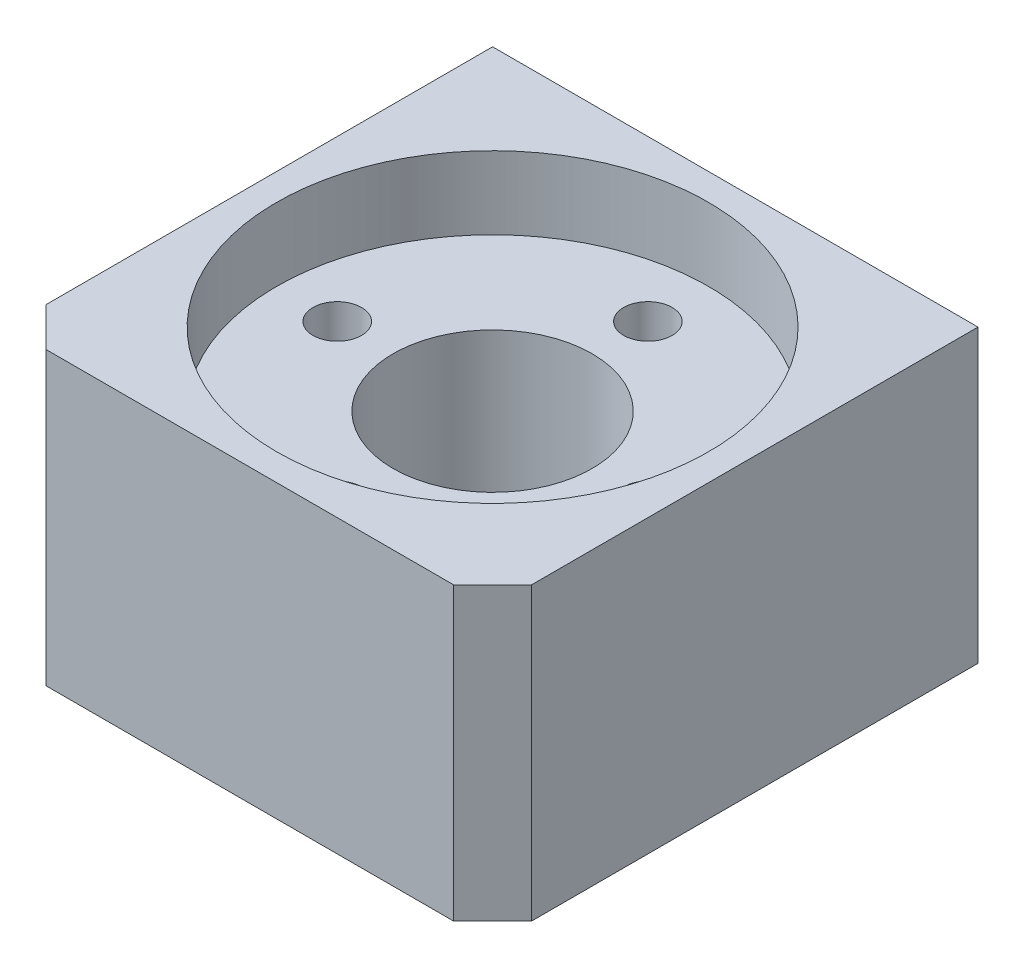
from build123d import *

# Parameters (mm, degrees)
SKETCH1_W                 = 25
SKETCH1_H                 = 25
BOSS_EXTRUDE1_DEPTH       = 15
SKETCH2_R                 = 11.125
CUT_EXTRUDE1_DEPTH        = 3.75
SKETCH3_R                 = 5.125
CUT_EXTRUDE2_DEPTH        = 12.25
M3X0_5_TAPPED_HOLE1_D     = 2.5
M3X0_5_TAPPED_HOLE1_DEPTH = 6
M3X0_5_TAPPED_HOLE1_TIP   = 0.751075774
M4X0_7_TAPPED_HOLE1_D     = 3.3
M4X0_7_TAPPED_HOLE1_DEPTH = 8
M4X0_7_TAPPED_HOLE1_TIP   = 0.991420021
CHAMFER1_SIZE             = 2


with BuildPart() as part:
    # Sketch1 → Boss-Extrude1 (new body)
    with BuildSketch(Plane(origin=(0, 0, 0), x_dir=(1, 0, 0), z_dir=(0, 1, 0))):
        Rectangle(SKETCH1_W, SKETCH1_H)
    extrude(amount=BOSS_EXTRUDE1_DEPTH)

    # Sketch2 → Cut-Extrude1 (cut)
    with BuildSketch(Plane(origin=(0, 15, 0), x_dir=(1, 0, 0), z_dir=(0, 1, 0))):
        Circle(SKETCH2_R)
    extrude(amount=-CUT_EXTRUDE1_DEPTH, mode=Mode.SUBTRACT)

    # Sketch3 → Cut-Extrude2 (cut, through all)
    with BuildSketch(Plane(origin=(0, 11.25, 0), x_dir=(1, 0, 0), z_dir=(0, 1, 0))):
        Circle(SKETCH3_R)
    extrude(amount=-CUT_EXTRUDE2_DEPTH, mode=Mode.SUBTRACT)

    # M3x0.5 Tapped Hole1
    with Locations(Plane(origin=(0, 11.25, 0), x_dir=(1, 0, 0), z_dir=(0, 1, 0))):
        with Locations((-8, 0), (8, 0), (0, 8), (0, -8)):
            Hole(M3X0_5_TAPPED_HOLE1_D / 2, depth=M3X0_5_TAPPED_HOLE1_DEPTH)
            with Locations((0, 0, -(M3X0_5_TAPPED_HOLE1_DEPTH + M3X0_5_TAPPED_HOLE1_TIP / 2))):  # 118° drill point
                Cone(0, M3X0_5_TAPPED_HOLE1_D / 2, M3X0_5_TAPPED_HOLE1_TIP, mode=Mode.SUBTRACT)

    # M4x0.7 Tapped Hole1
    with Locations(Plane(origin=(0, 0, -12.5), x_dir=(-1, 0, 0), z_dir=(0, 0, -1))):
        with Locations((-7.5, 7.5), (7.5, 7.5)):
            Hole(M4X0_7_TAPPED_HOLE1_D / 2, depth=M4X0_7_TAPPED_HOLE1_DEPTH)
            with Locations((0, 0, -(M4X0_7_TAPPED_HOLE1_DEPTH + M4X0_7_TAPPED_HOLE1_TIP / 2))):  # 118° drill point
                Cone(0, M4X0_7_TAPPED_HOLE1_D / 2, M4X0_7_TAPPED_HOLE1_TIP, mode=Mode.SUBTRACT)

    # Chamfer1
    chamfer1_edges = [part.edges().sort_by_distance(p)[0] for p in [
        (12.5, 7.5, 12.5),
        (-12.5, 7.5, 12.5),
    ]]
    chamfer(chamfer1_edges, length=CHAMFER1_SIZE)


solid = part.part
